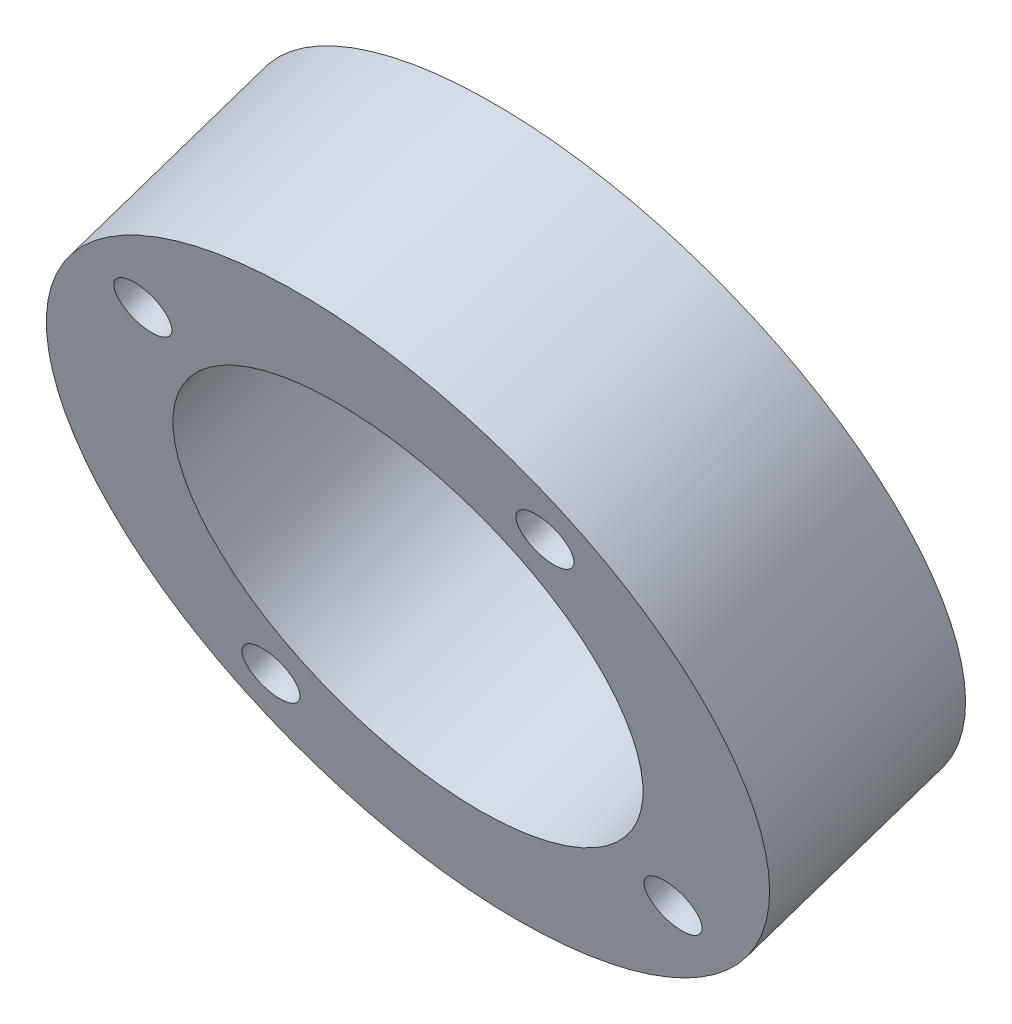
from build123d import *

# Parameters (mm, degrees)
SKETCH1_R               = 31.75
SKETCH1_R_2             = 20.6375
BOSS_EXTRUDE1_DEPTH     = 19.05
F_1_4_20_TAPPED_HOLE1_D = 5.1054


with BuildPart() as part:
    # Sketch1 → Boss-Extrude1 (new body)
    with BuildSketch(Plane(origin=(0, -336.500449063, 1001.043483969), x_dir=(1, 0, 0), z_dir=(0, -0.318629355, 0.947879388))):
        with Locations((0, 892.252904457)):
            Circle(SKETCH1_R)
        with Locations((0, 892.252904457)):
            Circle(SKETCH1_R_2, mode=Mode.SUBTRACT)
    extrude(amount=BOSS_EXTRUDE1_DEPTH)

    # 1/4-20 Tapped Hole1 (through all)
    with Locations(Plane(origin=(0, -336.500449063, 1001.043483969), x_dir=(-1, 0, 0), z_dir=(0, 0.318629355, -0.947879388))):
        with Locations((18.52177825, 910.774682707), (-18.52177825, 910.774682707), (-18.52177825, 873.731126207), (18.52177825, 873.731126207)):
            Hole(F_1_4_20_TAPPED_HOLE1_D / 2)


solid = part.part
